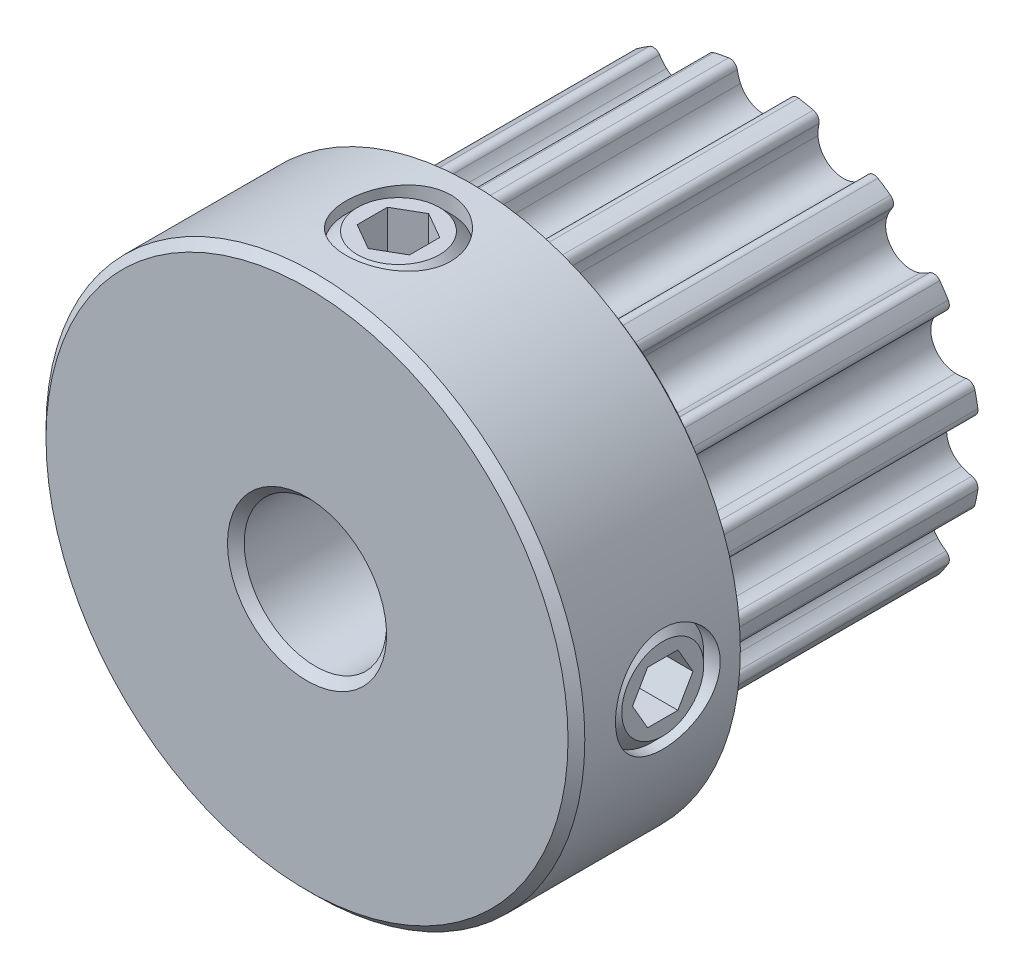
from build123d import *

# Parameters (mm, degrees)
CUT_EXTRUDE1_START = 2.655
CUT_EXTRUDE1_DEPTH = 10.16
CIRPATTERN1_COUNT  = 16
SKETCH4_R          = 1.7526
CUT_EXTRUDE2_DEPTH = 16.477114557
CUT_EXTRUDE3_DEPTH = 1.31445
CIRPATTERN3_COUNT  = 2
CIRPATTERN3_ANGLE  = 90
CHAMFER1_SIZE      = 0.28075
CUT_EXTRUDE5_START = -2.27
SKETCH8_R          = 9.015
CUT_EXTRUDE5_DEPTH = 2.27


with BuildPart() as part:
    # Sketch2 → Revolve1 (revolve)
    with BuildSketch(Plane(origin=(0, 0, 0), x_dir=(0, 0, -1), z_dir=(1, 0, 0)), mode=Mode.PRIVATE) as revolve1_sk:
        Polygon((-8.775, 2.38125), (8.775, 2.38125), (8.775, 9.015), (8.14, 9.015), (7.505, 8.13975), (7.505, 7.2645), (-2.655, 7.2645), (-2.655, 8.13975), (-3.29, 9.015), (-8.775, 9.015), align=None)
    revolve(revolve1_sk.sketch.rotate(Axis((0, 0, 8.775), (0, 0, -1)), 90), axis=Axis((0, 0, 8.775), (0, 0, -1)))

    # Sketch3 → Cut-Extrude1 (cut)
    with BuildSketch(Plane.XY.offset(CUT_EXTRUDE1_START)):
        with BuildLine():
            Line((3.757926927, 9.015), (-3.757926927, 9.015))
            Line((-3.757926927, 9.015), (-2.795101196, 6.705249403))
            ThreePointArc((-2.795101196, 6.705249403), (-1.995846132, 6.984952288), (-1.169472895, 7.169748489))
            ThreePointArc((-1.169472895, 7.169748489), (-0.985767742, 7.127751824), (-0.883573242, 6.969424355))
            ThreePointArc((-0.883573242, 6.969424355), (-0.839120956, 6.792881518), (-0.773880597, 6.622919538))
            ThreePointArc((-0.773880597, 6.622919538), (0, 6.1245), (0.773880597, 6.622919538))
            ThreePointArc((0.773880597, 6.622919538), (0.839120956, 6.792881518), (0.883573242, 6.969424355))
            ThreePointArc((0.883573242, 6.969424355), (0.985767742, 7.127751824), (1.169472895, 7.169748489))
            ThreePointArc((1.169472895, 7.169748489), (1.995846132, 6.984952288), (2.795101196, 6.705249403))
            Line((2.795101196, 6.705249403), (3.757926927, 9.015))
        make_face()
    cut_extrude1 = extrude(amount=-CUT_EXTRUDE1_DEPTH, mode=Mode.SUBTRACT)

    # CirPattern1: Cut-Extrude1 ×16 about axis
    cirpattern1_axis = Axis((0, 0, 0), (0, 0, 1))
    for i in range(1, CIRPATTERN1_COUNT):
        add(cut_extrude1.rotate(cirpattern1_axis, i * 360 / CIRPATTERN1_COUNT), mode=Mode.SUBTRACT)

    # Sketch4 → Cut-Extrude2 (cut, through all)
    with BuildSketch(Plane(origin=(0, 0, 0), x_dir=(0, -1, 0), z_dir=(1, 0, 0))):
        with Locations(Location((0, -5.715, 0), (0, 0, 270))):
            Circle(SKETCH4_R)
    cut_extrude2 = extrude(amount=CUT_EXTRUDE2_DEPTH, mode=Mode.SUBTRACT)

    # Sketch5 → Revolve2 (revolve)
    with BuildSketch(Plane.XY.offset(5.715), mode=Mode.PRIVATE) as revolve2_sk:
        Polygon((2.38125, -1.3716), (2.38125, 0), (8.842998261, 0), (8.842998261, -1.3716), (8.461998261, -1.7526), (2.76225, -1.7526), align=None)
    revolve2 = revolve(revolve2_sk.sketch.rotate(Axis((2.38125, 0, 5.715), (1, 0, 0)), 270), axis=Axis((2.38125, 0, 5.715), (1, 0, 0)))

    # Sketch6 → Cut-Extrude3 (cut)
    with BuildSketch(Plane(origin=(8.842998261, 5.384140679, 0), x_dir=(0, -1, 0), z_dir=(-1, 0, 0))):
        Polygon((5.384140679, 6.726864082), (4.507840679, 6.220932041), (4.507840679, 5.209067959), (5.384140679, 4.703135918), (6.260440679, 5.209067959), (6.260440679, 6.220932041), align=None)
    cut_extrude3 = extrude(amount=CUT_EXTRUDE3_DEPTH, mode=Mode.SUBTRACT)

    # CirPattern3: Cut-Extrude2, Revolve2, Cut-Extrude3 ×2 about axis
    cirpattern3_axis = Axis((0, 0, 0), (0, 0, 1))
    add([cut_extrude2.rotate(cirpattern3_axis, i * CIRPATTERN3_ANGLE / (CIRPATTERN3_COUNT - 1)) for i in range(1, CIRPATTERN3_COUNT)], mode=Mode.SUBTRACT)
    add([revolve2.rotate(cirpattern3_axis, i * CIRPATTERN3_ANGLE / (CIRPATTERN3_COUNT - 1)) for i in range(1, CIRPATTERN3_COUNT)])
    add([cut_extrude3.rotate(cirpattern3_axis, i * CIRPATTERN3_ANGLE / (CIRPATTERN3_COUNT - 1)) for i in range(1, CIRPATTERN3_COUNT)], mode=Mode.SUBTRACT)

    # Chamfer1
    chamfer1_edges = [part.edges().sort_by_distance(p)[0] for p in [
        (-2.38125, 0, 8.775),
        (-9.015, 0, 8.775),
    ]]
    chamfer(chamfer1_edges, length=CHAMFER1_SIZE)

    # Sketch8 → Cut-Extrude5 (cut)
    with BuildSketch(Plane(origin=(0, 0, -8.775), x_dir=(-1, 0, 0), z_dir=(0, 0, -1)).offset(CUT_EXTRUDE5_START)):
        with Locations(Location((0, 0, 0), (0, 0, 180))):
            Circle(SKETCH8_R)
    extrude(amount=CUT_EXTRUDE5_DEPTH, mode=Mode.SUBTRACT)


solid = part.part
